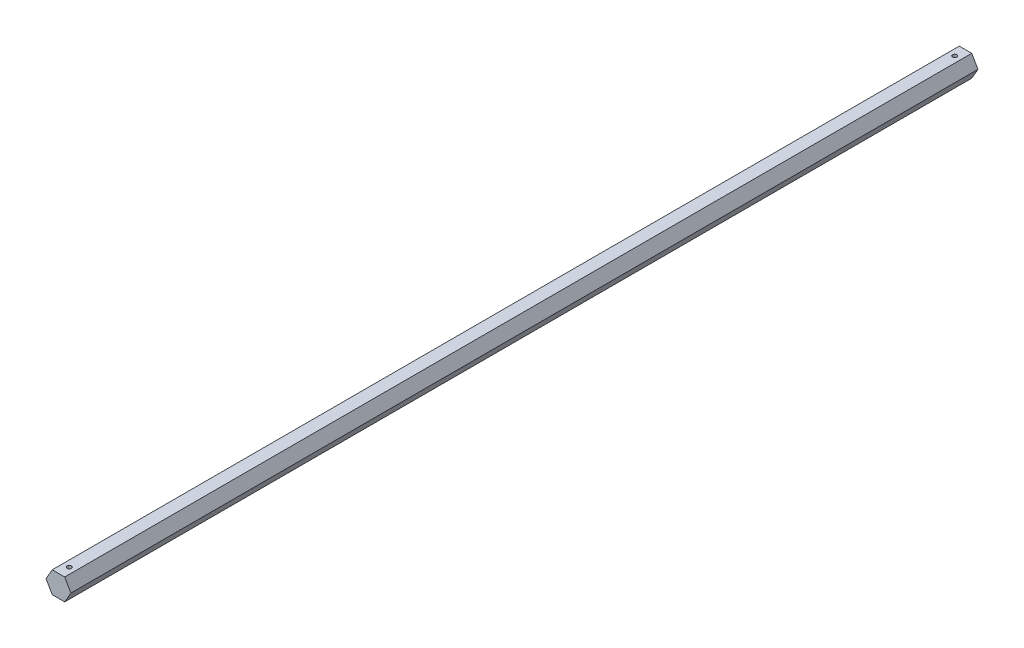
from build123d import *

# Parameters (mm, degrees)
BOSS_EXTRUDE1_DEPTH = 266.7
SKETCH2_R           = 1.2573
CUT_EXTRUDE1_DEPTH  = 13.7


with BuildPart() as part:
    # Sketch1 → Boss-Extrude1 (new body, symmetric)
    with BuildSketch(Plane.XY):
        Polygon((3.666174209, -6.35), (7.332348419, 0), (3.666174209, 6.35), (-3.666174209, 6.35), (-7.332348419, 0), (-3.666174209, -6.35), align=None)
    extrude(amount=BOSS_EXTRUDE1_DEPTH, both=True)

    # Sketch2 → Cut-Extrude1 (cut, through all)
    with BuildSketch(Plane(origin=(0, 6.35, 0), x_dir=(1, 0, 0), z_dir=(0, 1, 0))):
        with Locations((0, -260.35)):
            Circle(SKETCH2_R)
        with Locations((0, 260.35)):
            Circle(SKETCH2_R)
    extrude(amount=-CUT_EXTRUDE1_DEPTH, mode=Mode.SUBTRACT)


solid = part.part
